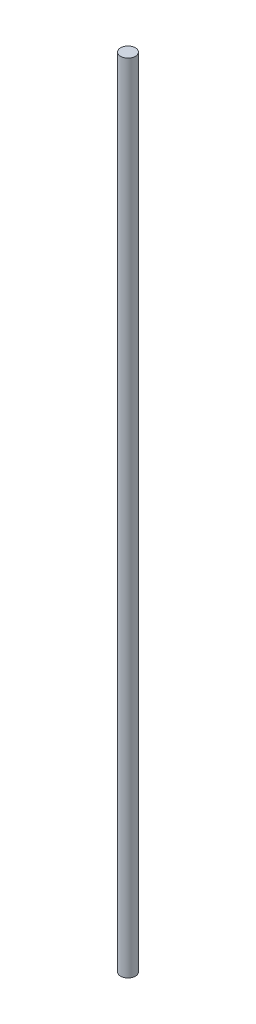
from build123d import *

# Parameters (mm, degrees)
SKETCH1_R           = 15.875
BOSS_EXTRUDE1_DEPTH = 1708.15


with BuildPart() as part:
    # Sketch1 → Boss-Extrude1 (new body)
    with BuildSketch(Plane(origin=(0, 0, 0), x_dir=(1, 0, 0), z_dir=(0, 1, 0))):
        Circle(SKETCH1_R)
    extrude(amount=BOSS_EXTRUDE1_DEPTH)


solid = part.part
